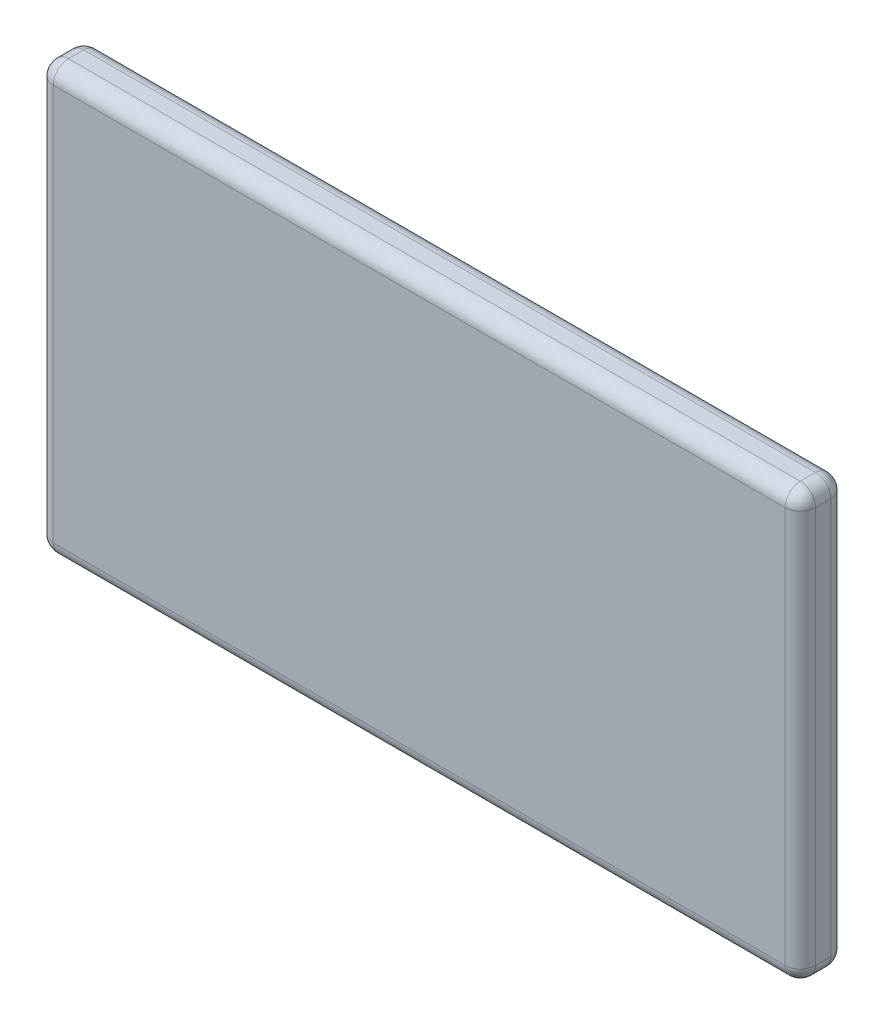
from build123d import *

# Parameters (mm, degrees)
SKETCH2_W           = 25
SKETCH2_H           = 14
BOSS_EXTRUDE1_DEPTH = 1.5
FILLET1_R           = 0.5


with BuildPart() as part:
    # Sketch2 → Boss-Extrude1 (new body)
    with BuildSketch(Plane.XY):
        Rectangle(SKETCH2_W, SKETCH2_H)
    extrude(amount=BOSS_EXTRUDE1_DEPTH)

    # Fillet1
    fillet1_edges = [part.edges().sort_by_distance(p)[0] for p in [
        (12.5, 0, 1.5),
        (0, 7, 1.5),
        (-12.5, 0, 1.5),
        (0, 7, 0),
        (12.5, 0, 0),
        (0, -7, 0),
        (-12.5, 0, 0),
        (0, -7, 1.5),
        (-12.5, 7, 0.75),
        (12.5, 7, 0.75),
        (12.5, -7, 0.75),
        (-12.5, -7, 0.75),
    ]]
    fillet(fillet1_edges, radius=FILLET1_R)


solid = part.part
